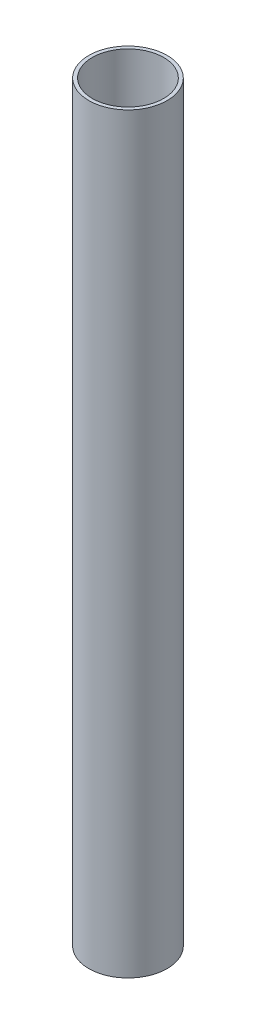
from build123d import *

# Parameters (mm, degrees)
SKETCH1_R           = 7.9375
SKETCH1_R_2         = 7.2263
BOSS_EXTRUDE1_DEPTH = 152.4


with BuildPart() as part:
    # Sketch1 → Boss-Extrude1 (new body)
    with BuildSketch(Plane(origin=(0, 0, 0), x_dir=(1, 0, 0), z_dir=(0, 1, 0))):
        Circle(SKETCH1_R)
        Circle(SKETCH1_R_2, mode=Mode.SUBTRACT)
    extrude(amount=BOSS_EXTRUDE1_DEPTH)


solid = part.part
